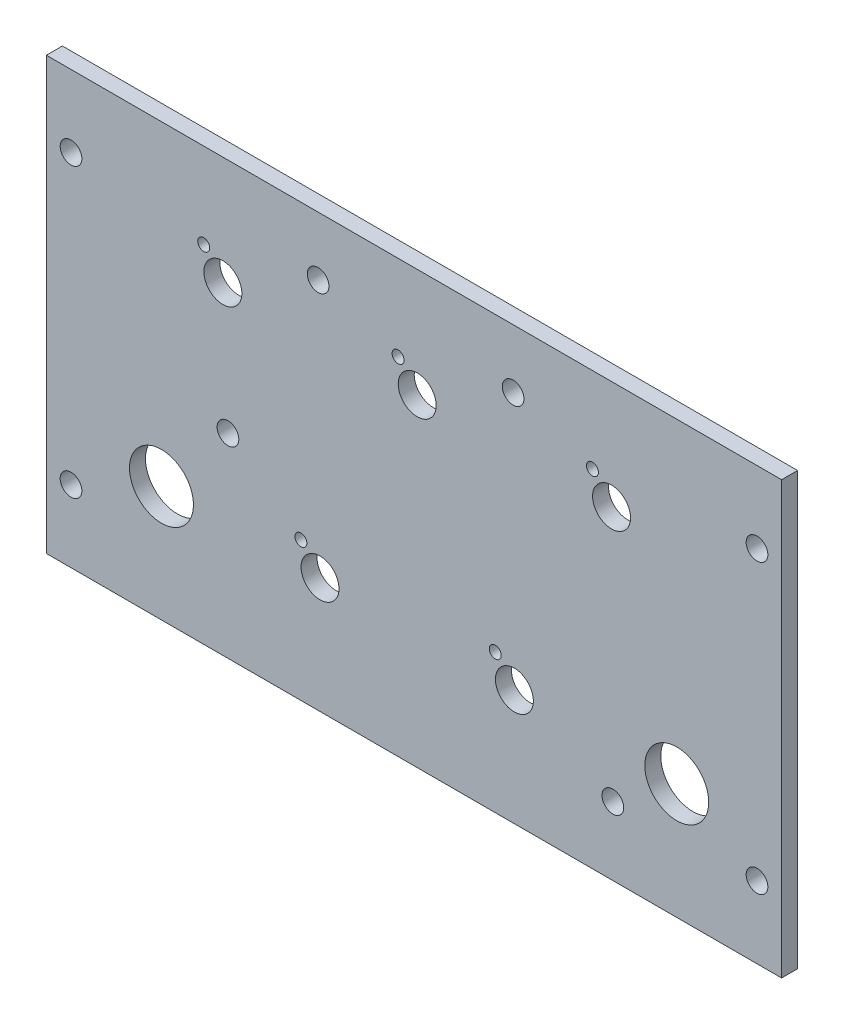
from build123d import *

# Parameters (mm, degrees)
SKETCH1_W                 = 146.05
SKETCH1_H                 = 85.725
BOSS_EXTRUDE1_DEPTH       = 3.175
F_6_CLEARANCE_HOLE1_D     = 4.3053
F_6_CLEARANCE_HOLE1_DEPTH = 12.7
F_6_CLEARANCE_HOLE1_TIP   = 1.293442612
SKETCH4_R                 = 6.35
SKETCH4_R_2               = 3.7703125
SKETCH4_R_3               = 1.190625
CUT_EXTRUDE1_DEPTH        = 4.175


with BuildPart() as part:
    # Sketch1 → Boss-Extrude1 (new body)
    with BuildSketch(Plane.XY):
        with Locations((-73.025, 42.8625)):
            Rectangle(SKETCH1_W, SKETCH1_H)
    extrude(amount=-BOSS_EXTRUDE1_DEPTH)

    # #6 Clearance Hole1
    with Locations(Plane(origin=(0, 0, -3.175), x_dir=(-1, 0, 0), z_dir=(0, 0, -1))):
        with Locations((4.8895, 71.4375), (53.34, 74.041), (92.075, 74.041), (141.1605, 71.4375), (109.982, 38.735), (141.1605, 14.2875), (33.528, 13.589), (4.8895, 14.2875)):
            Hole(F_6_CLEARANCE_HOLE1_D / 2, depth=F_6_CLEARANCE_HOLE1_DEPTH)
            with Locations((0, 0, -(F_6_CLEARANCE_HOLE1_DEPTH + F_6_CLEARANCE_HOLE1_TIP / 2))):  # 118° drill point
                Cone(0, F_6_CLEARANCE_HOLE1_D / 2, F_6_CLEARANCE_HOLE1_TIP, mode=Mode.SUBTRACT)

    # Sketch4 → Cut-Extrude1 (cut, through all)
    with BuildSketch(Plane(origin=(0, 0, -3.175), x_dir=(-1, 0, 0), z_dir=(0, 0, -1))):
        with Locations((20.828, 22.987)):
            Circle(SKETCH4_R)
        with Locations((123.19, 22.987)):
            Circle(SKETCH4_R)
        with Locations((33.782, 64.135)):
            Circle(SKETCH4_R_2)
        with Locations((72.39, 64.135)):
            Circle(SKETCH4_R_2)
        with Locations((110.998, 64.135)):
            Circle(SKETCH4_R_2)
        with Locations((91.694, 22.987)):
            Circle(SKETCH4_R_2)
        with Locations((53.086, 22.987)):
            Circle(SKETCH4_R_2)
        with Locations((37.582285256, 68.778041242)):
            Circle(SKETCH4_R_3)
        with Locations((76.190285256, 68.778041242)):
            Circle(SKETCH4_R_3)
        with Locations((114.798285256, 68.778041242)):
            Circle(SKETCH4_R_3)
        with Locations((56.886285256, 27.630041242)):
            Circle(SKETCH4_R_3)
        with Locations((95.494285256, 27.630041242)):
            Circle(SKETCH4_R_3)
    extrude(amount=-CUT_EXTRUDE1_DEPTH, mode=Mode.SUBTRACT)


solid = part.part
